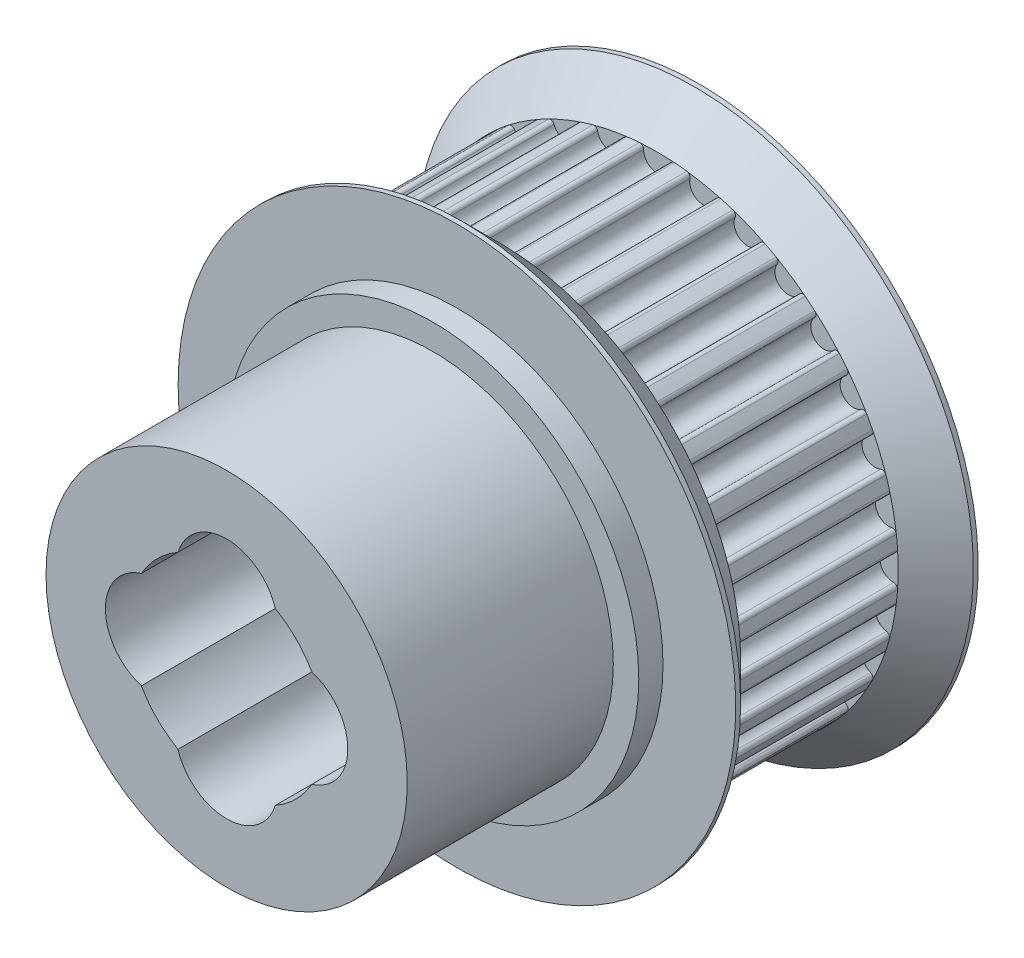
from build123d import *

# Parameters (mm, degrees)
SKETCH2_R           = 0.55
CUT_EXTRUDE1_DEPTH  = 6.5
FILLET1_R           = 0.16
SKETCH_1_R          = 7.45
EXTRUDE_1_DEPTH     = 9.5
SKETCH_3_R          = 4.05
CUT_EXTRUDE_2_DEPTH = 20.5
SKETCH_4_R          = 8.5
SKETCH_4_R_2        = 7.45
EXTRUDE_2_DEPTH     = 1


with BuildPart() as part:
    # Sketch1 → Revolve1 (revolve)
    with BuildSketch(Plane(origin=(0, 0, 0), x_dir=(0, 0, -1), z_dir=(1, 0, 0))):
        Polygon((-1.75, 9.95), (-8.25, 9.95), (-9.8, 11.5), (-10, 11.5), (-10, 2.55), (0, 2.55), (0, 11.5), (-0.2, 11.5), align=None)
    revolve(axis=Axis((0, 0, 0), (0, 0, 1)))

    # Sketch2 → Cut-Extrude1 (cut)
    with BuildSketch(Plane.XY.offset(1.75)):
        with Locations((0, 9.75)):
            Circle(SKETCH2_R)
        with Locations((1.90213064, 9.562656484)):
            Circle(SKETCH2_R)
        with Locations((3.731163466, 9.007825442)):
            Circle(SKETCH2_R)
        with Locations((5.416809772, 8.10682872)):
            Circle(SKETCH2_R)
        with Locations((6.894291117, 6.894291117)):
            Circle(SKETCH2_R)
        with Locations((8.10682872, 5.416809772)):
            Circle(SKETCH2_R)
        with Locations((9.007825442, 3.731163466)):
            Circle(SKETCH2_R)
        with Locations((9.562656484, 1.90213064)):
            Circle(SKETCH2_R)
        with Locations((9.75, 0)):
            Circle(SKETCH2_R)
        with Locations((9.562656484, -1.90213064)):
            Circle(SKETCH2_R)
        with Locations((9.007825442, -3.731163466)):
            Circle(SKETCH2_R)
        with Locations((8.10682872, -5.416809772)):
            Circle(SKETCH2_R)
        with Locations((6.894291117, -6.894291117)):
            Circle(SKETCH2_R)
        with Locations((5.416809772, -8.10682872)):
            Circle(SKETCH2_R)
        with Locations((3.731163466, -9.007825442)):
            Circle(SKETCH2_R)
        with Locations((1.90213064, -9.562656484)):
            Circle(SKETCH2_R)
        with Locations((0, -9.75)):
            Circle(SKETCH2_R)
        with Locations((-1.90213064, -9.562656484)):
            Circle(SKETCH2_R)
        with Locations((-3.731163466, -9.007825442)):
            Circle(SKETCH2_R)
        with Locations((-5.416809772, -8.10682872)):
            Circle(SKETCH2_R)
        with Locations((-6.894291117, -6.894291117)):
            Circle(SKETCH2_R)
        with Locations((-8.10682872, -5.416809772)):
            Circle(SKETCH2_R)
        with Locations((-9.007825442, -3.731163466)):
            Circle(SKETCH2_R)
        with Locations((-9.562656484, -1.90213064)):
            Circle(SKETCH2_R)
        with Locations((-9.75, 0)):
            Circle(SKETCH2_R)
        with Locations((-9.562656484, 1.90213064)):
            Circle(SKETCH2_R)
        with Locations((-9.007825442, 3.731163466)):
            Circle(SKETCH2_R)
        with Locations((-8.10682872, 5.416809772)):
            Circle(SKETCH2_R)
        with Locations((-6.894291117, 6.894291117)):
            Circle(SKETCH2_R)
        with Locations((-5.416809772, 8.10682872)):
            Circle(SKETCH2_R)
        with Locations((-3.731163466, 9.007825442)):
            Circle(SKETCH2_R)
        with Locations((-1.90213064, 9.562656484)):
            Circle(SKETCH2_R)
    extrude(amount=CUT_EXTRUDE1_DEPTH, mode=Mode.SUBTRACT)

    # Fillet1
    fillet1_edges = [part.edges().sort_by_distance(p)[0] for p in [
        (-8.982163863, 4.280564488, 5),
        (-9.378165154, 3.324532801, 5),
        (-9.644670808, 2.445981401, 5),
        (-9.846550515, 1.431063575, 5),
        (-9.936538462, 0.517400621, 5),
        (-9.936538462, -0.517400621, 5),
        (-9.846550515, -1.431063575, 5),
        (-9.644670808, -2.445981401, 5),
        (-9.378165154, -3.324532801, 5),
        (-8.982163863, -4.280564488, 5),
        (-8.549382166, -5.090242095, 5),
        (-7.974477399, -5.950647882, 5),
        (-7.392051215, -6.66033624, 5),
        (-6.66033624, -7.392051215, 5),
        (-5.950647882, -7.974477399, 5),
        (-5.090242095, -8.549382166, 5),
        (-4.280564488, -8.982163863, 5),
        (-3.324532801, -9.378165154, 5),
        (-2.445981401, -9.644670808, 5),
        (-1.431063575, -9.846550515, 5),
        (-0.517400621, -9.936538462, 5),
        (0.517400621, -9.936538462, 5),
        (1.431063575, -9.846550515, 5),
        (2.445981401, -9.644670808, 5),
        (3.324532801, -9.378165154, 5),
        (4.280564488, -8.982163863, 5),
        (5.090242095, -8.549382166, 5),
        (5.950647882, -7.974477399, 5),
        (6.66033624, -7.392051215, 5),
        (7.392051215, -6.66033624, 5),
        (7.974477399, -5.950647882, 5),
        (8.549382166, -5.090242095, 5),
        (8.982163863, -4.280564488, 5),
        (9.378165154, -3.324532801, 5),
        (9.644670808, -2.445981401, 5),
        (9.846550515, -1.431063575, 5),
        (9.936538462, -0.517400621, 5),
        (9.936538462, 0.517400621, 5),
        (9.846550515, 1.431063575, 5),
        (9.644670808, 2.445981401, 5),
        (9.378165154, 3.324532801, 5),
        (8.982163863, 4.280564488, 5),
        (8.549382166, 5.090242095, 5),
        (7.974477399, 5.950647882, 5),
        (7.392051215, 6.66033624, 5),
        (6.66033624, 7.392051215, 5),
        (5.950647882, 7.974477399, 5),
        (5.090242095, 8.549382166, 5),
        (4.280564488, 8.982163863, 5),
        (3.324532801, 9.378165154, 5),
        (2.445981401, 9.644670808, 5),
        (1.431063575, 9.846550515, 5),
        (0.517400621, 9.936538462, 5),
        (-0.517400621, 9.936538462, 5),
        (-1.431063575, 9.846550515, 5),
        (-2.445981401, 9.644670808, 5),
        (-3.324532801, 9.378165154, 5),
        (-4.280564488, 8.982163863, 5),
        (-5.090242095, 8.549382166, 5),
        (-5.950647882, 7.974477399, 5),
        (-6.66033624, 7.392051215, 5),
        (-7.392051215, 6.66033624, 5),
        (-7.974477399, 5.950647882, 5),
        (-8.549382166, 5.090242095, 5),
    ]]
    fillet(fillet1_edges, radius=FILLET1_R)

    # 草图1 → 凸台-拉伸1 (add)
    with BuildSketch(Plane.XY.offset(10)):
        Circle(SKETCH_1_R)
    extrude(amount=EXTRUDE_1_DEPTH)

    # 草图3 → 切除-拉伸2 (cut, through all)
    with BuildSketch(Plane.XY.offset(19.5)):
        Circle(SKETCH_3_R)
        with BuildLine():
            ThreePointArc((-2.007107568, 3.517672414), (0, 4.05), (2.007107568, 3.517672414))
            ThreePointArc((2.007107568, 3.517672414), (0, 5), (-2.007107568, 3.517672414))
        make_face()
        with BuildLine():
            ThreePointArc((3.517672414, 2.007107568), (3.914656644, 1.038250144), (4.05, 0))
            ThreePointArc((4.05, 0), (3.914656644, -1.038250144), (3.517672414, -2.007107568))
            ThreePointArc((3.517672414, -2.007107568), (5, 0), (3.517672414, 2.007107568))
        make_face()
        with BuildLine():
            ThreePointArc((-2.007107568, -3.517672414), (0, -5), (2.007107568, -3.517672414))
            ThreePointArc((2.007107568, -3.517672414), (0, -4.05), (-2.007107568, -3.517672414))
        make_face()
        with BuildLine():
            ThreePointArc((-3.517672414, -2.007107568), (-4.05, 0), (-3.517672414, 2.007107568))
            ThreePointArc((-3.517672414, 2.007107568), (-5, 0), (-3.517672414, -2.007107568))
        make_face()
    extrude(amount=-CUT_EXTRUDE_2_DEPTH, mode=Mode.SUBTRACT)

    # 草图4 → 凸台-拉伸2 (add)
    with BuildSketch(Plane.XY.offset(10)):
        Circle(SKETCH_4_R)
        Circle(SKETCH_4_R_2, mode=Mode.SUBTRACT)
    extrude(amount=EXTRUDE_2_DEPTH)


solid = part.part
